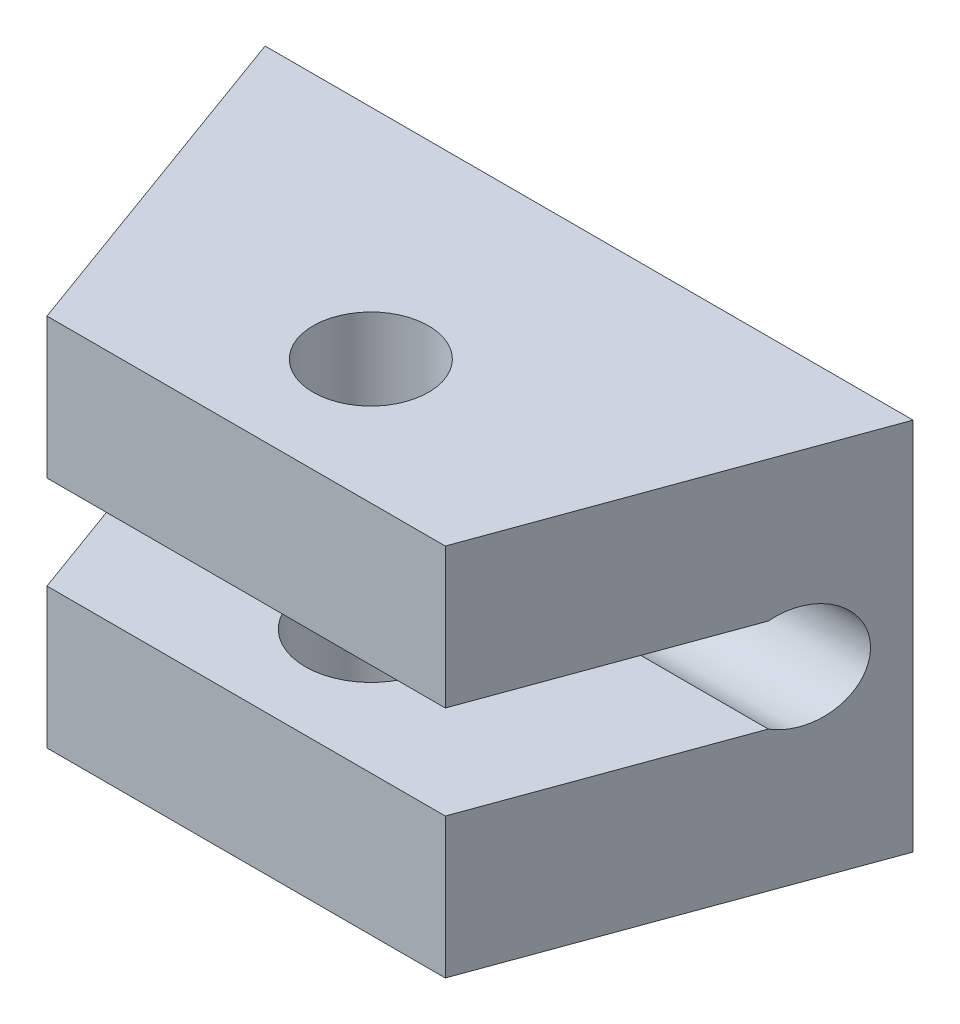
from build123d import *

# Parameters (mm, degrees)
SKETCH8_W           = 10.392304846
SKETCH8_H           = 6
BOSS_EXTRUDE3_DEPTH = 5.5
CUT_EXTRUDE5_DEPTH  = 11.392304845
CUT_EXTRUDE7_REACH  = 8
SKETCH11_R          = 0.925
CUT_EXTRUDE8_REACH  = 4.25
SKETCH12_R          = 1.05
CUT_EXTRUDE6_DEPTH  = 7


with BuildPart() as part:
    # Sketch8 → Boss-Extrude3 (new body)
    with BuildSketch(Plane.XY):
        Rectangle(SKETCH8_W, SKETCH8_H)
    extrude(amount=BOSS_EXTRUDE3_DEPTH)

    # Sketch9 → Cut-Extrude5 (cut, through all)
    with BuildSketch(Plane(origin=(5.196152423, 0, 0), x_dir=(0, 0, -1), z_dir=(1, 0, 0))):
        with BuildLine():
            Line((-1.702049043, 0.75), (-5.5, 0.75))
            Line((-5.5, 0.75), (-5.5, -0.75))
            Line((-5.5, -0.75), (-1.702049043, -0.75))
            ThreePointArc((-1.702049043, -0.75), (-0.5, 0), (-1.702049043, 0.75))
        make_face()
    extrude(amount=-CUT_EXTRUDE5_DEPTH, mode=Mode.SUBTRACT)

    # Sketch11 → Cut-Extrude7 (cut, up to next)
    with BuildSketch(Plane(origin=(0, 3, 0), x_dir=(1, 0, 0), z_dir=(0, 1, 0)), mode=Mode.PRIVATE) as cut_extrude7_sk1:
        with Locations((0, -3.5)):
            Circle(SKETCH11_R)
    cut_extrude7_tool1 = extrude(cut_extrude7_sk1.sketch, amount=-CUT_EXTRUDE7_REACH, mode=Mode.PRIVATE) & part.part
    add(cut_extrude7_tool1.solids().sort_by_distance((0, 3, 3.5))[0], mode=Mode.SUBTRACT)

    # Sketch12 → Cut-Extrude8 (cut, up to next)
    with BuildSketch(Plane(origin=(0, -0.75, 0), x_dir=(1, 0, 0), z_dir=(0, 1, 0)), mode=Mode.PRIVATE) as cut_extrude8_sk1:
        with Locations((0, -3.5)):
            Circle(SKETCH12_R)
    cut_extrude8_tool1 = extrude(cut_extrude8_sk1.sketch, amount=-CUT_EXTRUDE8_REACH, mode=Mode.PRIVATE) & part.part
    add(cut_extrude8_tool1.solids().sort_by_distance((0, -0.75, 3.5))[0], mode=Mode.SUBTRACT)

    # Sketch10 → Cut-Extrude6 (cut, through all)
    with BuildSketch(Plane.XZ.offset(3)):
        Polygon((5.196152423, 0), (3.194316134, 5.5), (5.196152423, 5.5), align=None)
        Polygon((-5.196152423, 5.5), (-5.196152423, 0), (-3.194316134, 5.5), align=None)
    extrude(amount=-CUT_EXTRUDE6_DEPTH, mode=Mode.SUBTRACT)


solid = part.part
